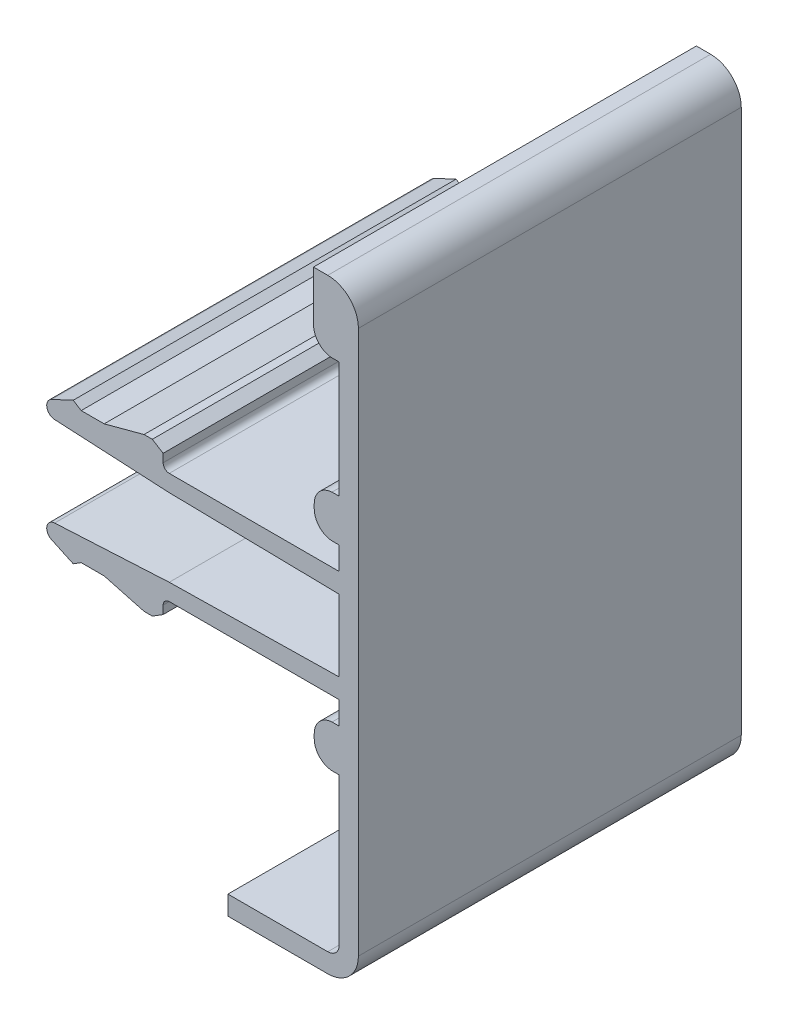
from build123d import *

# Parameters (mm, degrees)
MAIN_EXTRUSION_DEPTH = 25


with BuildPart() as part:
    # Sk Main Extrusion → Main Extrusion (new body)
    with BuildSketch(Plane.XY):
        with BuildLine():
            Line((-3.83, 2.5328), (-11.31249103, 2.925083334))
            ThreePointArc((-11.31249103, 2.925083334), (-11.819967595, 3.366238681), (-11.514691833, 3.965369062))
            Line((-11.514691833, 3.965369062), (-10.100108722, 4.625))
            Line((-10.100108722, 4.625), (-9.58, 4.3))
            Line((-9.58, 4.3), (-8.08, 4.3))
            Line((-8.08, 4.3), (-5.474147193, 5))
            Line((-5.474147193, 5), (-4.934147193, 5))
            Line((-4.934147193, 5), (-4.23, 4.56))
            Line((-4.23, 4.56), (-4.23, 4.025))
            ThreePointArc((-4.23, 4.025), (-4.112842712, 3.742157288), (-3.83, 3.625))
            Line((-3.83, 3.625), (7.27, 3.625))
            Line((7.27, 3.625), (7.27, 5.120055168))
            Line((7.27, 5.120055168), (6.79886836, 5.120055168))
            ThreePointArc((6.79886836, 5.120055168), (5.9740485, 5.504367154), (5.638, 6.35))
            Line((5.638, 6.35), (5.638, 6.65))
            ThreePointArc((5.638, 6.65), (5.9740485, 7.495632846), (6.79886836, 7.879944832))
            Line((6.79886836, 7.879944832), (7.27, 7.879944832))
            Line((7.27, 7.879944832), (7.27, 15.470020156))
            Line((7.27, 15.470020156), (6.798058361, 15.470020156))
            ThreePointArc((6.798058361, 15.470020156), (5.938401057, 15.86929153), (5.588, 16.75))
            Line((5.588, 16.75), (5.588, 20))
            Line((5.588, 20), (6.52, 20))
            ThreePointArc((6.52, 20), (7.934213562, 19.414213562), (8.52, 18))
            Line((8.52, 18), (8.52, -17.5))
            ThreePointArc((8.52, -17.5), (7.934213562, -18.914213562), (6.52, -19.5))
            Line((6.52, -19.5), (0, -19.5))
            Line((0, -19.5), (0, -18.25))
            Line((0, -18.25), (6.52, -18.25))
            ThreePointArc((6.52, -18.25), (7.050330086, -18.030330086), (7.27, -17.5))
            Line((7.27, -17.5), (7.27, -7.879944832))
            Line((7.27, -7.879944832), (6.79886836, -7.879944832))
            ThreePointArc((6.79886836, -7.879944832), (5.9740485, -7.495632846), (5.638, -6.65))
            Line((5.638, -6.65), (5.638, -6.35))
            ThreePointArc((5.638, -6.35), (5.9740485, -5.504367154), (6.79886836, -5.120055168))
            Line((6.79886836, -5.120055168), (7.27, -5.120055168))
            Line((7.27, -5.120055168), (7.27, -3.625))
            Line((7.27, -3.625), (-3.83, -3.625))
            ThreePointArc((-3.83, -3.625), (-4.112842712, -3.742157288), (-4.23, -4.025))
            Line((-4.23, -4.025), (-4.23, -4.56))
            Line((-4.23, -4.56), (-4.934147193, -5))
            Line((-4.934147193, -5), (-5.474147193, -5))
            Line((-5.474147193, -5), (-8.08, -4.3))
            Line((-8.08, -4.3), (-9.58, -4.3))
            Line((-9.58, -4.3), (-10.100108722, -4.625))
            Line((-10.100108722, -4.625), (-11.514691833, -3.965369062))
            ThreePointArc((-11.514691833, -3.965369062), (-11.819967595, -3.366238681), (-11.31249103, -2.925083334))
            Line((-11.31249103, -2.925083334), (-3.83, -2.5328))
            Line((-3.83, -2.5328), (7.27, -2.339048779))
            Line((7.27, -2.339048779), (7.27, 2.339048779))
            Line((7.27, 2.339048779), (-3.83, 2.5328))
        make_face()
    extrude(amount=-MAIN_EXTRUSION_DEPTH)


solid = part.part
